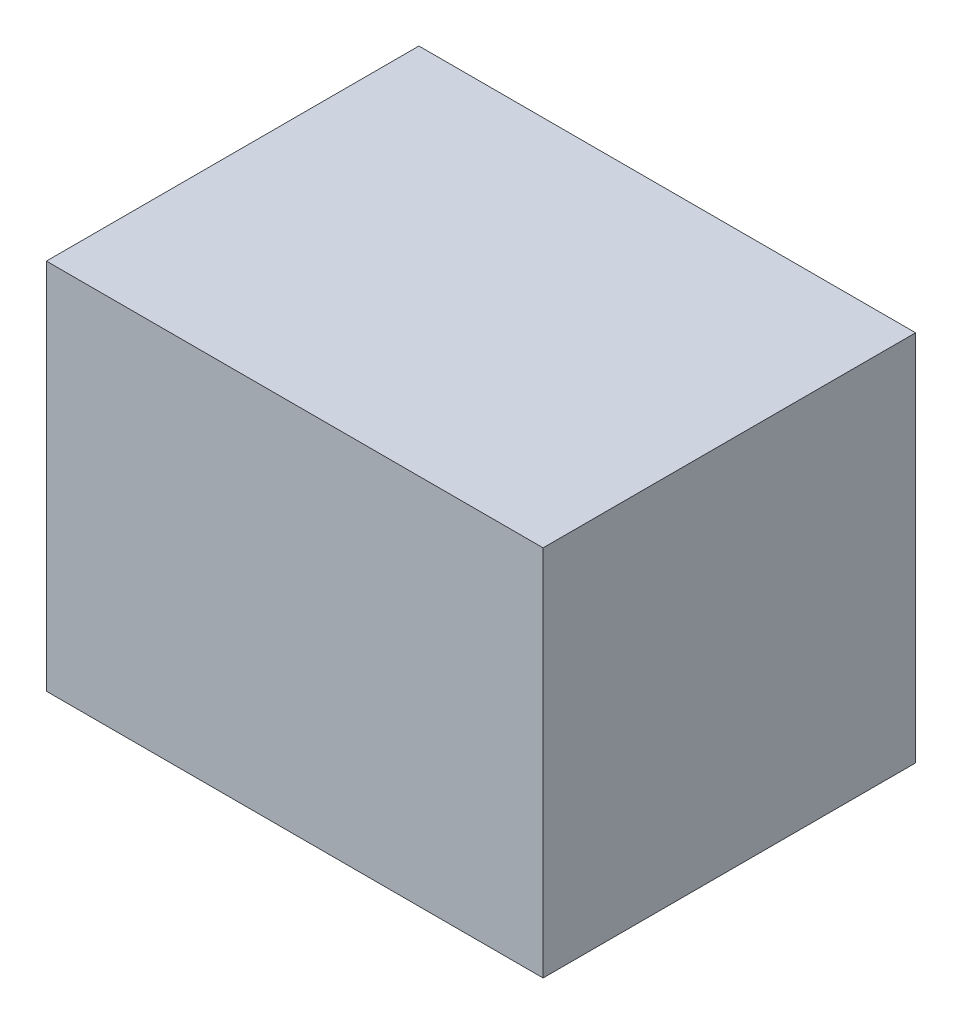
from build123d import *

# Parameters (mm, degrees)
CROQUIS1_W              = 40
CROQUIS1_H              = 30
SALIENTE_EXTRUIR1_DEPTH = 30


with BuildPart() as part:
    # Croquis1 → Saliente-Extruir1 (new body)
    with BuildSketch(Plane(origin=(0, 0, 0), x_dir=(1, 0, 0), z_dir=(0, 1, 0))):
        Rectangle(CROQUIS1_W, CROQUIS1_H)
    extrude(amount=SALIENTE_EXTRUIR1_DEPTH)


solid = part.part
